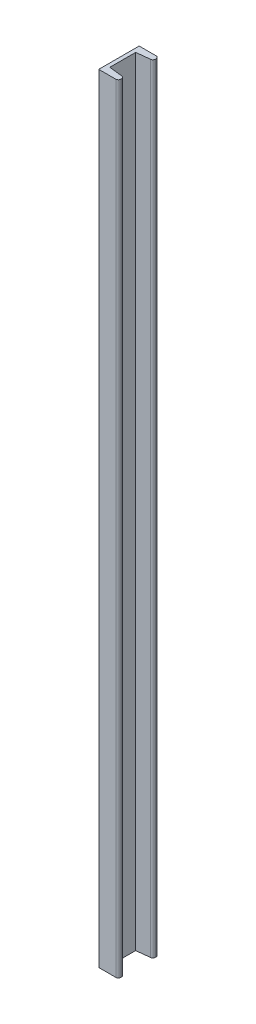
from build123d import *

# Parameters (mm, degrees)
BOSS_EXTRU_1_DEPTH = 155


with BuildPart() as part:
    # Esquisse1 → Boss.-Extru.1 (new body)
    with BuildSketch(Plane(origin=(0, 0, 0), x_dir=(1, 0, 0), z_dir=(0, 1, 0))):
        with BuildLine():
            Line((0.75, 6.6), (3.455215763, 6.900579529))
            ThreePointArc((3.455215763, 6.900579529), (3.772564009, 7.064060665), (3.9, 7.397521397))
            Line((3.9, 7.397521397), (3.9, 7.55))
            ThreePointArc((3.9, 7.55), (3.753553391, 7.903553391), (3.4, 8.05))
            Line((3.4, 8.05), (0, 8.05))
            Line((0, 8.05), (0, 0))
            Line((0, 0), (3.4, 0))
            ThreePointArc((3.4, 0), (3.753553391, 0.146446609), (3.9, 0.5))
            Line((3.9, 0.5), (3.9, 0.652478603))
            ThreePointArc((3.9, 0.652478603), (3.772564009, 0.985939335), (3.455215763, 1.149420471))
            Line((3.455215763, 1.149420471), (0.75, 1.45))
            Line((0.75, 1.45), (0.75, 6.6))
        make_face()
    extrude(amount=BOSS_EXTRU_1_DEPTH)


solid = part.part
